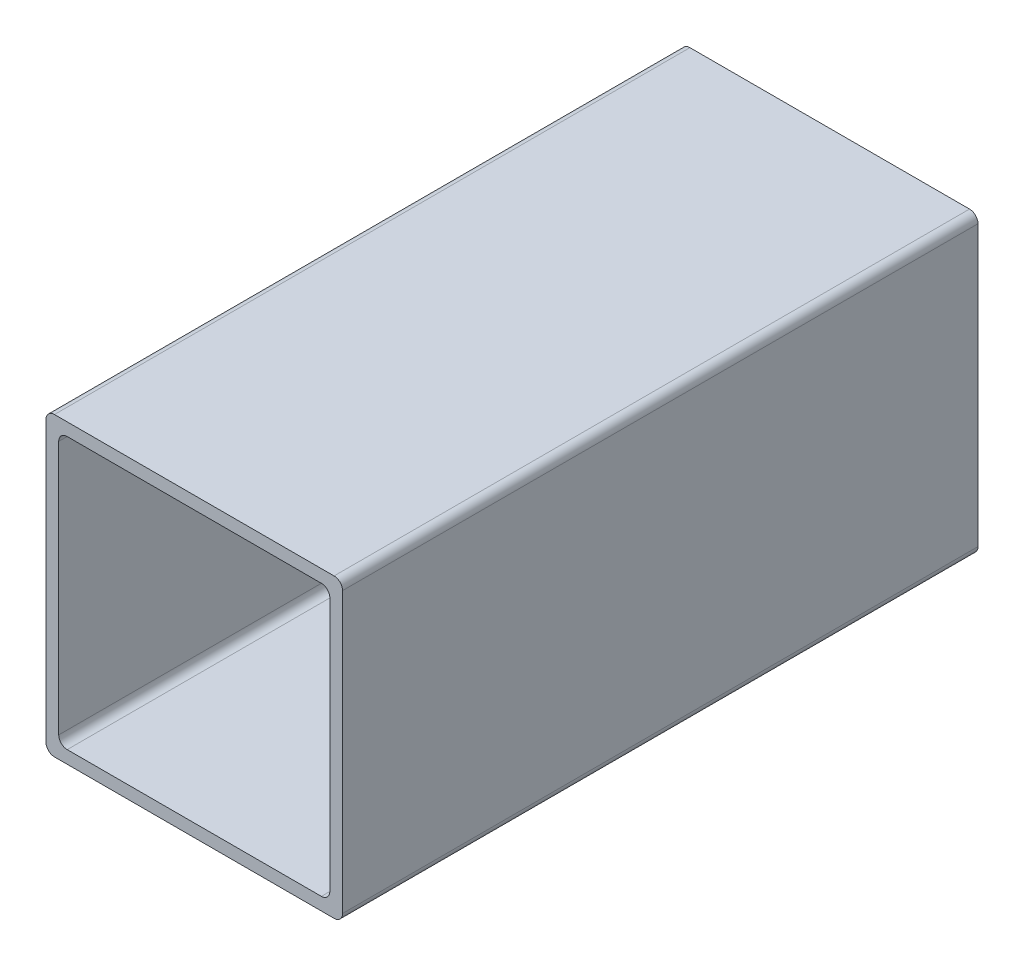
from build123d import *

# Parameters (mm, degrees)
SKETCH_1_W      = 70
SKETCH_1_H      = 70
SKETCH_1_W_2    = 64
SKETCH_1_H_2    = 64
EXTRUDE_1_DEPTH = 150
FILLET_1_R      = 2


with BuildPart() as part:
    # 草图1 → 凸台-拉伸1 (new body)
    with BuildSketch(Plane.XY):
        Rectangle(SKETCH_1_W, SKETCH_1_H)
        Rectangle(SKETCH_1_W_2, SKETCH_1_H_2, mode=Mode.SUBTRACT)
    extrude(amount=EXTRUDE_1_DEPTH)

    # 圆角1
    fillet_1_edges = [part.edges().sort_by_distance(p)[0] for p in [
        (32, -32, 75),
        (32, 32, 75),
        (-32, 32, 75),
        (-32, -32, 75),
        (35, -35, 75),
        (-35, -35, 75),
        (-35, 35, 75),
        (35, 35, 75),
    ]]
    fillet(fillet_1_edges, radius=FILLET_1_R)


solid = part.part
